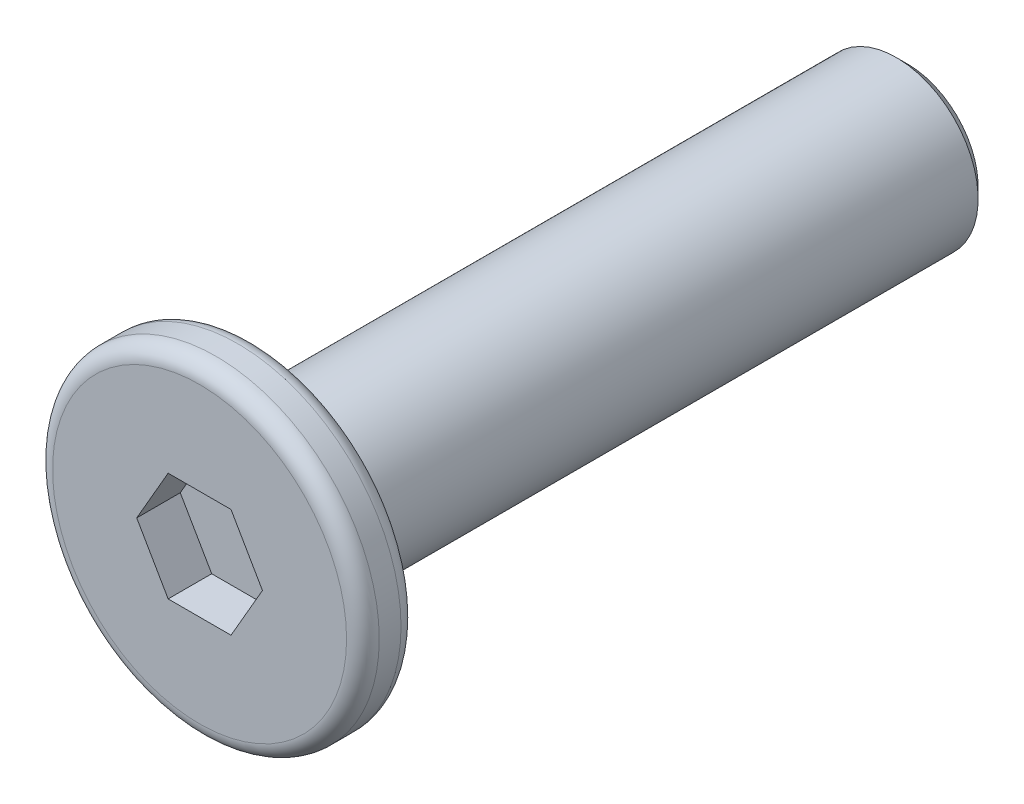
from build123d import *

# Parameters (mm, degrees)
SKETCH_1_R          = 3
EXTRUDE_1_DEPTH     = 0.5
SKETCH_2_R          = 1.5
EXTRUDE_2_DEPTH     = 12
CHAMFER_1_SIZE      = 0.2
CUT_EXTRUDE_1_DEPTH = 0.8
FILLET_2_R          = 0.3


with BuildPart() as part:
    # 草图1 → 凸台-拉伸1 (new body, symmetric)
    with BuildSketch(Plane.XY):
        Circle(SKETCH_1_R)
    extrude(amount=EXTRUDE_1_DEPTH, both=True)

    # 草图2 → 凸台-拉伸2 (add)
    with BuildSketch(Plane(origin=(0, 0, -0.5), x_dir=(-1, 0, 0), z_dir=(0, 0, -1))):
        Circle(SKETCH_2_R)
    extrude(amount=EXTRUDE_2_DEPTH)

    # 倒角1
    chamfer_1_edges = [part.edges().sort_by_distance(p)[0] for p in [
        (1.5, 0, -12.5),
    ]]
    chamfer(chamfer_1_edges, length=CHAMFER_1_SIZE)

    # 草图3 → 切除-拉伸1 (cut)
    with BuildSketch(Plane.XY.offset(0.5)):
        Polygon((1.154700538, 0), (0.577350269, 1), (-0.577350269, 1), (-1.154700538, 0), (-0.577350269, -1), (0.577350269, -1), align=None)
    extrude(amount=-CUT_EXTRUDE_1_DEPTH, mode=Mode.SUBTRACT)

    # 圆角2
    fillet_2_edges = [part.edges().sort_by_distance(p)[0] for p in [
        (-3, 0, -0.5),
        (-3, 0, 0.5),
    ]]
    fillet(fillet_2_edges, radius=FILLET_2_R)


solid = part.part
